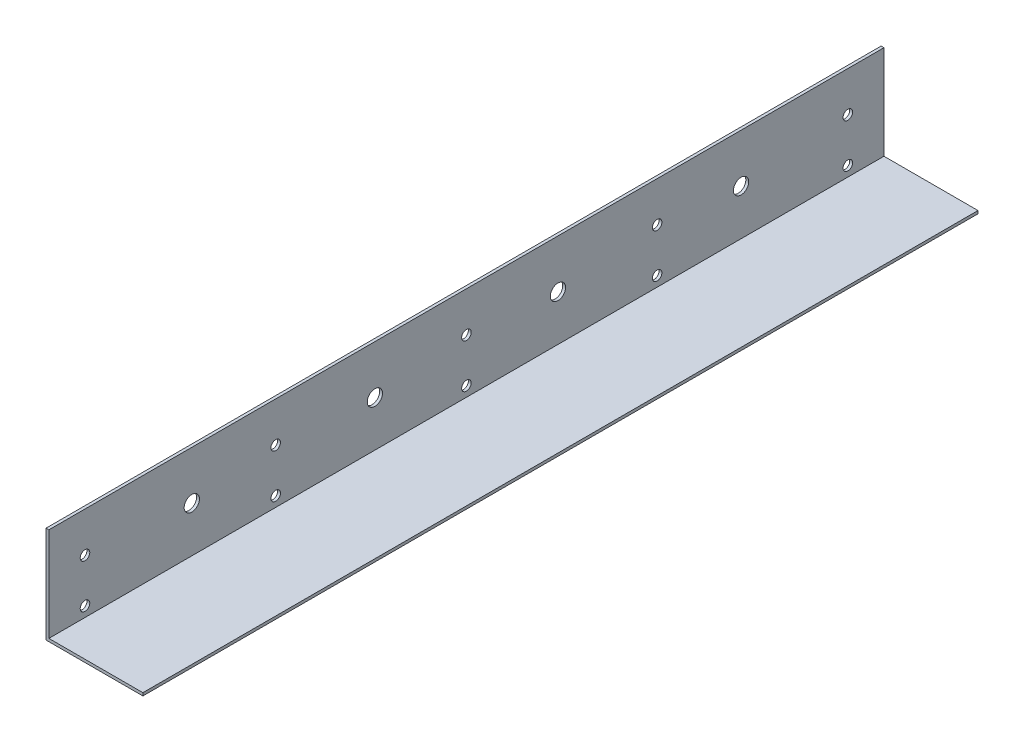
from build123d import *

# Parameters (mm, degrees)
SALIENTE_EXTRUIR1_DEPTH = 437.896
CROQUIS2_R              = 3.999992
CORTAR_EXTRUIR1_DEPTH   = 4.064
CROQUIS3_R              = 2.5
CORTAR_EXTRUIR2_DEPTH   = 1.499997


with BuildPart() as part:
    # Croquis1 → Saliente-Extruir1 (new body)
    with BuildSketch(Plane.XY):
        Polygon((0, 0), (0, 50.8), (1.499997, 50.8), (1.499997, 1.499997), (50.8, 1.499997), (50.8, 0), align=None)
    extrude(amount=SALIENTE_EXTRUIR1_DEPTH)

    # Croquis2 → Cortar-Extruir1 (cut)
    with BuildSketch(Plane.ZY):
        with Locations((266.948, 25.4)):
            Circle(CROQUIS2_R)
        with Locations((362.948, 25.4)):
            Circle(CROQUIS2_R)
        with Locations((74.948, 25.4)):
            Circle(CROQUIS2_R)
        with Locations((170.948, 25.4)):
            Circle(CROQUIS2_R)
    extrude(amount=-CORTAR_EXTRUIR1_DEPTH, mode=Mode.SUBTRACT)

    # Croquis3 → Cortar-Extruir2 (cut)
    with BuildSketch(Plane.ZY):
        with Locations((18.948, 29.8)):
            Circle(CROQUIS3_R)
        with Locations((118.948, 29.8)):
            Circle(CROQUIS3_R)
        with Locations((218.948, 29.8)):
            Circle(CROQUIS3_R)
        with Locations((318.948, 29.8)):
            Circle(CROQUIS3_R)
        with Locations((418.948, 29.8)):
            Circle(CROQUIS3_R)
        with Locations((18.948, 6.8)):
            Circle(CROQUIS3_R)
        with Locations((218.948, 6.8)):
            Circle(CROQUIS3_R)
        with Locations((118.948, 6.8)):
            Circle(CROQUIS3_R)
        with Locations((318.948, 6.8)):
            Circle(CROQUIS3_R)
        with Locations((418.948, 6.8)):
            Circle(CROQUIS3_R)
    extrude(amount=-CORTAR_EXTRUIR2_DEPTH, mode=Mode.SUBTRACT)


solid = part.part
